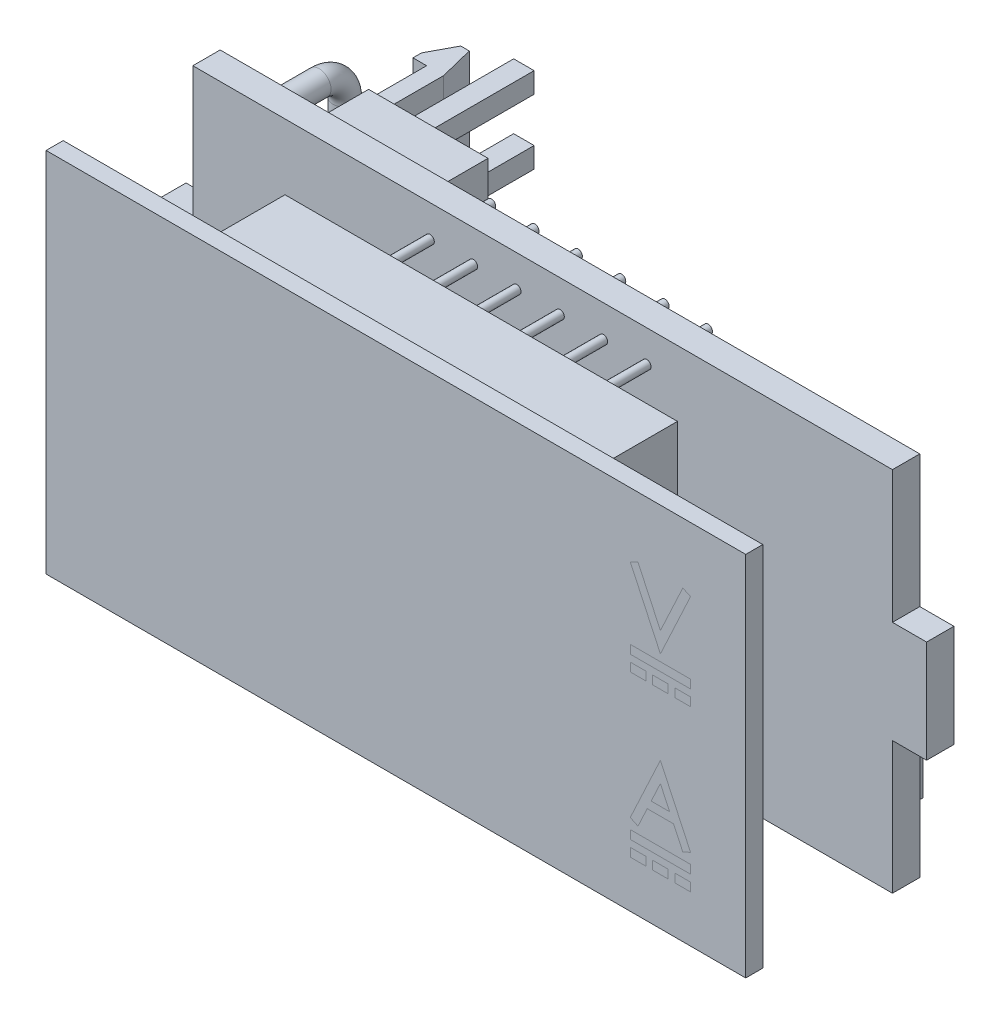
from build123d import *

# Parameters (mm, degrees)
BOSS_EXTRU_1_DEPTH              = 1.6
BOSS_EXTRU_2_START              = -1
ESQUISSE2_W                     = 23
ESQUISSE2_H                     = 21
BOSS_EXTRU_2_DEPTH              = 4
ESQUISSE4_W                     = 41
ESQUISSE4_H                     = 21.5
BOSS_EXTRU_3_DEPTH              = 1
ESQUISSE8_W                     = 7
ESQUISSE8_H                     = 8
BOSS_EXTRU_4_DEPTH              = 3.6
ESQUISSE9_W                     = 1.2
ESQUISSE9_H                     = 1.2
BOSS_EXTRU_5_DEPTH              = 7.3
BOSS_EXTRU_6_DEPTH              = 2.5
ESQUISSE11_W                    = 10
ESQUISSE11_H                    = 6.5
BOSS_EXTRU_7_DEPTH              = 7
ESQUISSE12_W                    = 8.6
ESQUISSE12_H                    = 5.1
ENL_V_MAT_EXTRU_1_DEPTH         = 5.7
ESQUISSE13_W                    = 1.5
ESQUISSE13_H                    = 0.7
ESQUISSE13_W_2                  = 0.7
ESQUISSE13_H_2                  = 1
ENL_V_MAT_EXTRU_2_DEPTH         = 5
ESQUISSE14_W                    = 0.8
ESQUISSE14_H                    = 0.6
BOSS_EXTRU_8_DEPTH              = 5
ESQUISSE15_R                    = 0.7
ESQUISSE17_W                    = 4.3
ESQUISSE17_H                    = 6.6
BOSS_EXTRU_9_DEPTH              = 1
ESQUISSE18_W                    = 4.4
ESQUISSE18_H                    = 2.2
BOSS_EXTRU_10_DEPTH             = 1.5
ESQUISSE19_W                    = 3.5
ESQUISSE19_H                    = 4.8
BOSS_EXTRU_11_DEPTH             = 1.5
BOSS_EXTRU_12_DEPTH             = 0.7
BOSS_EXTRU_13_START             = -5.2
ESQUISSE21_R                    = 0.25
BOSS_EXTRU_13_DEPTH             = 7.2
R_P_TITION_LIN_AIRE2_COUNT      = 6
R_P_TITION_LIN_AIRE2_PITCH      = 2.54
R_P_TITION_LIN_AIRE2_COUNT_DIR2 = 2
R_P_TITION_LIN_AIRE2_PITCH_DIR2 = 7.62
BOSS_EXTRU_14_START             = -5.2
ESQUISSE22_R                    = 0.25
BOSS_EXTRU_14_DEPTH             = 7.2
R_P_TITION_LIN_AIRE3_COUNT      = 6
R_P_TITION_LIN_AIRE3_PITCH      = 2.54
R_P_TITION_LIN_AIRE3_COUNT_DIR2 = 2
R_P_TITION_LIN_AIRE3_PITCH_DIR2 = 7.62


with BuildPart() as part:
    # Esquisse1 → Boss.-Extru.1 (new body)
    with BuildSketch(Plane.XY.offset(-10.2)):
        Polygon((-20.5, -3), (-20.5, -10.75), (20.5, -10.75), (20.5, -3), (22.5, -3), (22.5, 3), (20.5, 3), (20.5, 10.75), (-20.5, 10.75), (-20.5, 3), (-22.5, 3), (-22.5, -3), align=None)
    extrude(amount=BOSS_EXTRU_1_DEPTH)

    # Esquisse17 → Boss.-Extru.9 (add)
    with BuildSketch(Plane(origin=(0, 0, -10.2), x_dir=(-1, 0, 0), z_dir=(0, 0, -1))):
        with Locations((-15, 4.35)):
            Rectangle(ESQUISSE17_W, ESQUISSE17_H)
    extrude(amount=BOSS_EXTRU_9_DEPTH)

    # Esquisse18 → Boss.-Extru.10 (add)
    with BuildSketch(Plane(origin=(0, 0, -10.2), x_dir=(-1, 0, 0), z_dir=(0, 0, -1))):
        with Locations((-17, -7)):
            Rectangle(ESQUISSE18_W, ESQUISSE18_H)
    extrude(amount=BOSS_EXTRU_10_DEPTH)

    # Esquisse19 → Boss.-Extru.11 (add)
    with BuildSketch(Plane(origin=(0, 0, -10.2), x_dir=(-1, 0, 0), z_dir=(0, 0, -1))):
        with Locations((12.55, -1.5)):
            Rectangle(ESQUISSE19_W, ESQUISSE19_H)
    extrude(amount=BOSS_EXTRU_11_DEPTH)

    # Esquisse21 → Boss.-Extru.13 (add)
    with BuildSketch(Plane(origin=(0, 0, -10.2), x_dir=(-1, 0, 0), z_dir=(0, 0, -1)).offset(BOSS_EXTRU_13_START)):
        with Locations((6.6, 8.89)):
            Circle(ESQUISSE21_R)
    boss_extru_13 = extrude(amount=BOSS_EXTRU_13_DEPTH)

    # Répétition linéaire2: Boss.-Extru.13 6 × 2, 1 skipped
    with Locations(*[(i * R_P_TITION_LIN_AIRE2_PITCH, -j * R_P_TITION_LIN_AIRE2_PITCH_DIR2, 0) for i in range(R_P_TITION_LIN_AIRE2_COUNT) for j in range(R_P_TITION_LIN_AIRE2_COUNT_DIR2) if (i, j) not in ((0, 0), (5, 1))]):
        add(boss_extru_13)

    # Esquisse22 → Boss.-Extru.14 (add)
    with BuildSketch(Plane(origin=(0, 0, -10.2), x_dir=(-1, 0, 0), z_dir=(0, 0, -1)).offset(BOSS_EXTRU_14_START)):
        with Locations((6.6, -1.27)):
            Circle(ESQUISSE22_R)
    boss_extru_14 = extrude(amount=BOSS_EXTRU_14_DEPTH)

    # Répétition linéaire3: Boss.-Extru.14 6 × 2, 1 skipped
    with Locations(*[(i * R_P_TITION_LIN_AIRE3_PITCH, -j * R_P_TITION_LIN_AIRE3_PITCH_DIR2, 0) for i in range(R_P_TITION_LIN_AIRE3_COUNT) for j in range(R_P_TITION_LIN_AIRE3_COUNT_DIR2) if (i, j) not in ((0, 0), (5, 1))]):
        add(boss_extru_14)


with BuildPart() as body_2:
    # Esquisse2 → Boss.-Extru.2 (new body)
    with BuildSketch(Plane.XY.offset(BOSS_EXTRU_2_START)):
        Rectangle(ESQUISSE2_W, ESQUISSE2_H)
    extrude(amount=-BOSS_EXTRU_2_DEPTH)


with BuildPart() as body_3:
    # Esquisse4 → Boss.-Extru.3 (new body)
    with BuildSketch(Plane.XY):
        Rectangle(ESQUISSE4_W, ESQUISSE4_H)
    extrude(amount=-BOSS_EXTRU_3_DEPTH)


with BuildPart() as body_4:
    # Esquisse8 → Boss.-Extru.4 (new body)
    with BuildSketch(Plane(origin=(0, 0, -10.2), x_dir=(-1, 0, 0), z_dir=(0, 0, -1))):
        with Locations((11.9, 5.5)):
            Rectangle(ESQUISSE8_W, ESQUISSE8_H)
    extrude(amount=BOSS_EXTRU_4_DEPTH)

    # Esquisse9 → Boss.-Extru.5 (add)
    with BuildSketch(Plane(origin=(0, 0, -13.8), x_dir=(-1, 0, 0), z_dir=(0, 0, -1))):
        with Locations((13.6, 3.6)):
            Rectangle(ESQUISSE9_W, ESQUISSE9_H)
        with Locations((13.6, 7.4)):
            Rectangle(ESQUISSE9_W, ESQUISSE9_H)
    extrude(amount=BOSS_EXTRU_5_DEPTH)

    # Esquisse10 → Boss.-Extru.6 (add, symmetric)
    with BuildSketch(Plane(origin=(0, 5.5, 0), x_dir=(1, 0, 0), z_dir=(0, 1, 0))):
        Polygon((-15.9, 20.2), (-16.4, 20.2), (-17.2, 18.7), (-17.2, 18.2), (-16.4, 18.2), (-16.4, 10.2), (-15.4, 10.2), (-15.4, 18.2), align=None)
    extrude(amount=BOSS_EXTRU_6_DEPTH, both=True)


with BuildPart() as body_5:
    # Esquisse11 → Boss.-Extru.7 (new body)
    with BuildSketch(Plane(origin=(0, 0, -10.2), x_dir=(-1, 0, 0), z_dir=(0, 0, -1))):
        with Locations((15.5, -7.5)):
            Rectangle(ESQUISSE11_W, ESQUISSE11_H)
    extrude(amount=BOSS_EXTRU_7_DEPTH)

    # Esquisse12 → Enlèv. mat.-Extru.1 (cut)
    with BuildSketch(Plane(origin=(0, 0, -17.2), x_dir=(-1, 0, 0), z_dir=(0, 0, -1))):
        with Locations((15.5, -7.5)):
            Rectangle(ESQUISSE12_W, ESQUISSE12_H)
    extrude(amount=-ENL_V_MAT_EXTRU_1_DEPTH, mode=Mode.SUBTRACT)

    # Esquisse13 → Enlèv. mat.-Extru.2 (cut)
    with BuildSketch(Plane(origin=(0, 0, -17.2), x_dir=(-1, 0, 0), z_dir=(0, 0, -1))):
        with Locations((13.25, -4.6)):
            Rectangle(ESQUISSE13_W, ESQUISSE13_H)
        with Locations((10.85, -5.45)):
            Rectangle(ESQUISSE13_W_2, ESQUISSE13_H_2)
        with Locations((20.15, -5.45)):
            Rectangle(ESQUISSE13_W_2, ESQUISSE13_H_2)
        with Locations((17.75, -4.6)):
            Rectangle(ESQUISSE13_W, ESQUISSE13_H)
    extrude(amount=-ENL_V_MAT_EXTRU_2_DEPTH, mode=Mode.SUBTRACT)

    # Esquisse14 → Boss.-Extru.8 (add)
    with BuildSketch(Plane(origin=(0, 0, -11.5), x_dir=(-1, 0, 0), z_dir=(0, 0, -1))):
        with Locations((13.2, -6.95)):
            Rectangle(ESQUISSE14_W, ESQUISSE14_H)
        with Locations((15.5, -6.95)):
            Rectangle(ESQUISSE14_W, ESQUISSE14_H)
        with Locations((17.8, -6.95)):
            Rectangle(ESQUISSE14_W, ESQUISSE14_H)
    extrude(amount=BOSS_EXTRU_8_DEPTH)

    # Esquisse20 → Boss.-Extru.12 (add)
    with BuildSketch(Plane(origin=(0, -4.25, 0), x_dir=(1, 0, 0), z_dir=(0, 1, 0))):
        Polygon((-12.5, 17.2), (-12.8, 16.9), (-12.5, 16.6), align=None)
        Polygon((-18.5, 16.6), (-18.5, 17.2), (-18.2, 16.9), align=None)
    extrude(amount=-BOSS_EXTRU_12_DEPTH)


with BuildPart() as body_6:
    # Balayage1: sweep along a path in Esquisse16
    with BuildLine(Plane(origin=(-18.2, 0, 0), x_dir=(0, -1, 0), z_dir=(-1, 0, 0))) as balayage1_path:
        Line((-8.5, -10.2), (-8.5, -13.7))
        ThreePointArc((-8.5, -13.7), (-8.060660172, -14.760660172), (-7, -15.2))
        Line((-7, -15.2), (0, -15.2))
        ThreePointArc((0, -15.2), (1.060660172, -14.760660172), (1.5, -13.7))
        Line((1.5, -13.7), (1.5, -10.2))
    # Esquisse15 → Balayage1 (sweep)
    with BuildSketch(Plane(origin=(0, 0, -10.2), x_dir=(-1, 0, 0), z_dir=(0, 0, -1))):
        with Locations((18.2, 8.5)):
            Circle(ESQUISSE15_R)
    sweep(path=balayage1_path.line)


solid = Compound([part.part, body_2.part, body_3.part, body_4.part, body_5.part, body_6.part])
